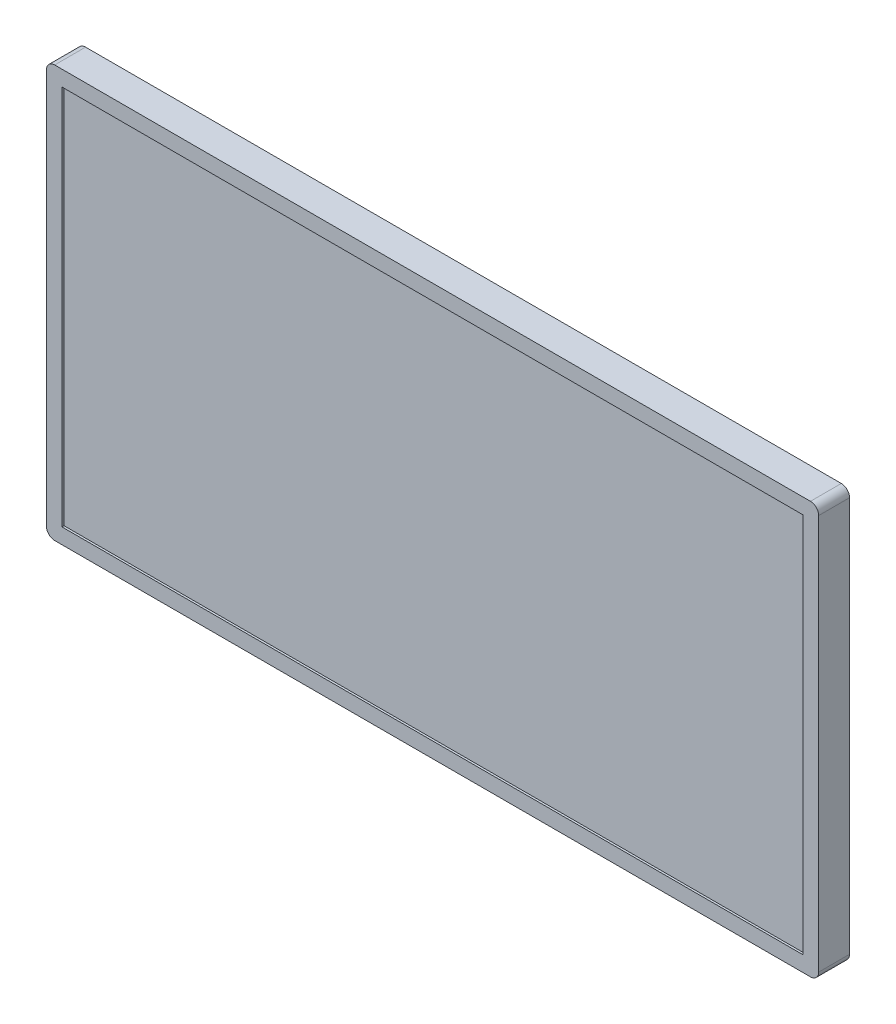
from build123d import *

# Parameters (mm, degrees)
CROQUIS1_W              = 750
CROQUIS1_H              = 400
SALIENTE_EXTRUIR1_DEPTH = 30
CROQUIS2_W              = 720
CROQUIS2_H              = 370
CORTAR_EXTRUIR1_DEPTH   = 2
REDONDEO1_R             = 8


with BuildPart() as part:
    # Croquis1 → Saliente-Extruir1 (new body)
    with BuildSketch(Plane.XY):
        with Locations((375, 200)):
            Rectangle(CROQUIS1_W, CROQUIS1_H)
    extrude(amount=SALIENTE_EXTRUIR1_DEPTH)

    # Croquis2 → Cortar-Extruir1 (cut)
    with BuildSketch(Plane.XY.offset(30)):
        with Locations((375, 200)):
            Rectangle(CROQUIS2_W, CROQUIS2_H)
    extrude(amount=-CORTAR_EXTRUIR1_DEPTH, mode=Mode.SUBTRACT)

    # Redondeo1
    redondeo1_edges = [part.edges().sort_by_distance(p)[0] for p in [
        (0, 400, 15),
        (750, 400, 15),
        (750, 0, 15),
        (0, 0, 15),
    ]]
    fillet(redondeo1_edges, radius=REDONDEO1_R)


solid = part.part
